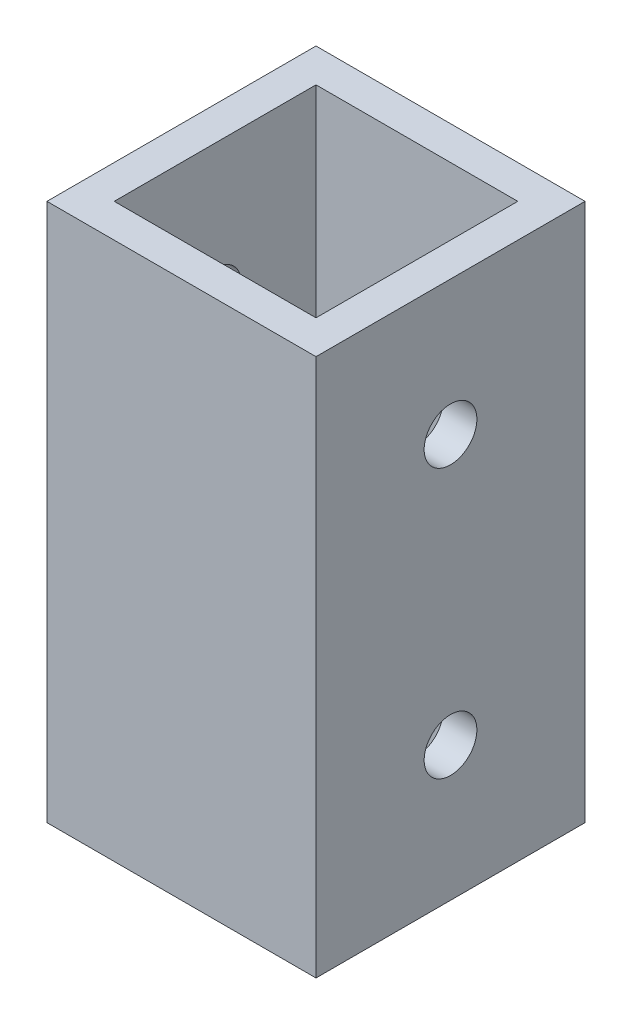
from build123d import *

# Parameters (mm, degrees)
SKETCH1_W           = 25.4
SKETCH1_H           = 25.4
SKETCH1_W_2         = 19.05
SKETCH1_H_2         = 19.05
EXTRUDE_THIN1_DEPTH = 25.4
SKETCH2_R           = 2.4892
CUT_EXTRUDE1_DEPTH  = 26.4


with BuildPart() as part:
    # Sketch1 → Extrude-Thin1 (new body, symmetric)
    with BuildSketch(Plane(origin=(0, 0, 0), x_dir=(1, 0, 0), z_dir=(0, 1, 0))):
        Rectangle(SKETCH1_W, SKETCH1_H)
        Rectangle(SKETCH1_W_2, SKETCH1_H_2, mode=Mode.SUBTRACT)
    extrude(amount=EXTRUDE_THIN1_DEPTH, both=True)

    # Sketch2 → Cut-Extrude1 (cut, through all)
    with BuildSketch(Plane(origin=(12.7, 0, 0), x_dir=(0, 0, -1), z_dir=(1, 0, 0))):
        with Locations((0, 12.7)):
            Circle(SKETCH2_R)
        with Locations((0, -12.7)):
            Circle(SKETCH2_R)
    extrude(amount=-CUT_EXTRUDE1_DEPTH, mode=Mode.SUBTRACT)


solid = part.part
